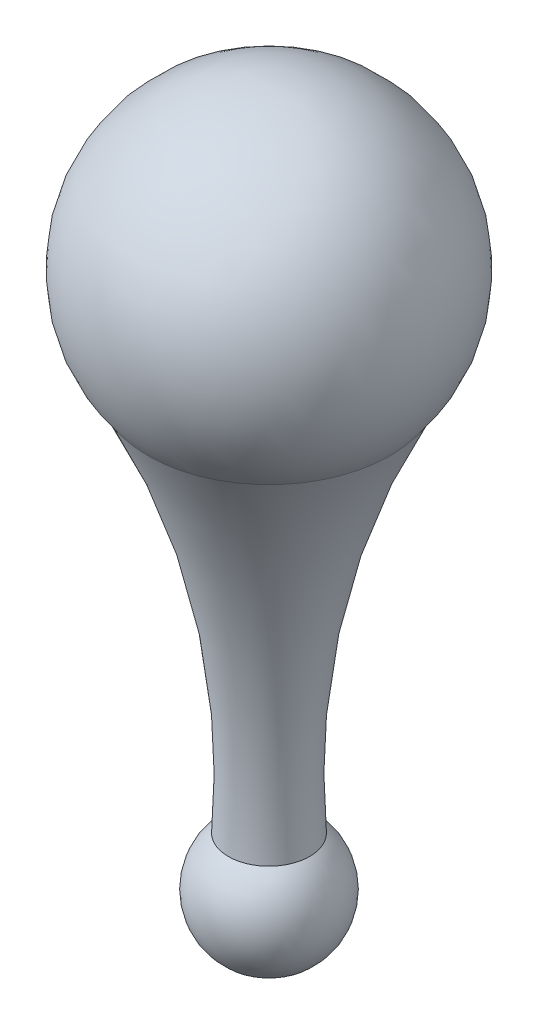
from build123d import *


with BuildPart() as part:
    # Sketch1 → Revolve1 (revolve)
    with BuildSketch(Plane.XY):
        with BuildLine():
            Line((0, 127), (0, -127))
            Line((0, -127), (0, -381))
            Line((0, -381), (0, -482.6))
            ThreePointArc((0, -482.6), (47.736385136, -449.174623281), (32.653610572, -392.88494229))
            ThreePointArc((32.653610572, -392.88494229), (43.3928279, -232.778661491), (97.287644276, -81.63402643))
            ThreePointArc((97.287644276, -81.63402643), (115.101088954, 53.672519241), (0, 127))
        make_face()
    revolve(axis=Axis((0, 127, 0), (0, -1, 0)))


solid = part.part
